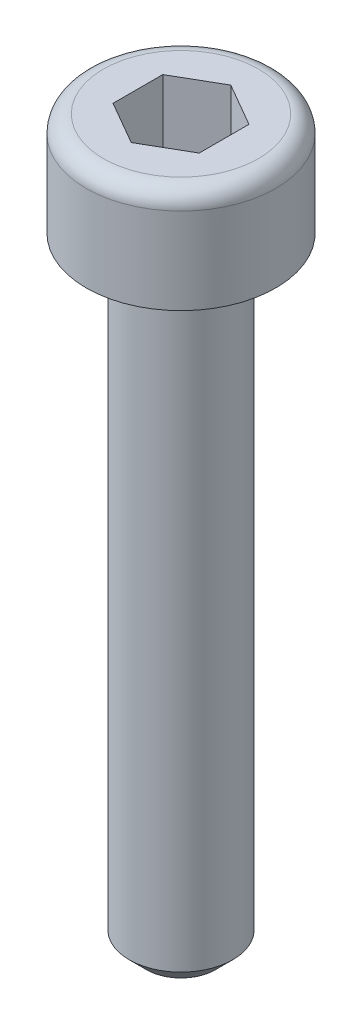
from build123d import *

# Parameters (mm, degrees)
CORTAR_EXTRUIR1_DEPTH = 2
CHAFL_N1_SIZE         = 0.5
REDONDEO1_R           = 0.5


with BuildPart() as part:
    # Croquis1 → Revolución1 (revolve)
    with BuildSketch(Plane.XY):
        Polygon((0, 0), (2.75, 0), (2.75, -3), (1.5, -3), (1.5, -21), (0, -21), align=None)
    revolve(axis=Axis((0, 0, 0), (0, -1, 0)))

    # Croquis2 → Cortar-Extruir1 (cut)
    with BuildSketch(Plane(origin=(0, 0, 0), x_dir=(1, 0, 0), z_dir=(0, 1, 0))):
        Polygon((1.25, 0.721687836), (0, 1.443375673), (-1.25, 0.721687836), (-1.25, -0.721687836), (0, -1.443375673), (1.25, -0.721687836), align=None)
    extrude(amount=-CORTAR_EXTRUIR1_DEPTH, mode=Mode.SUBTRACT)

    # Chaflán1
    chafl_n1_edges = [part.edges().sort_by_distance(p)[0] for p in [
        (-1.5, -21, 0),
    ]]
    chamfer(chafl_n1_edges, length=CHAFL_N1_SIZE)

    # Redondeo1
    redondeo1_edges = [part.edges().sort_by_distance(p)[0] for p in [
        (-2.75, 0, 0),
    ]]
    fillet(redondeo1_edges, radius=REDONDEO1_R)


solid = part.part
